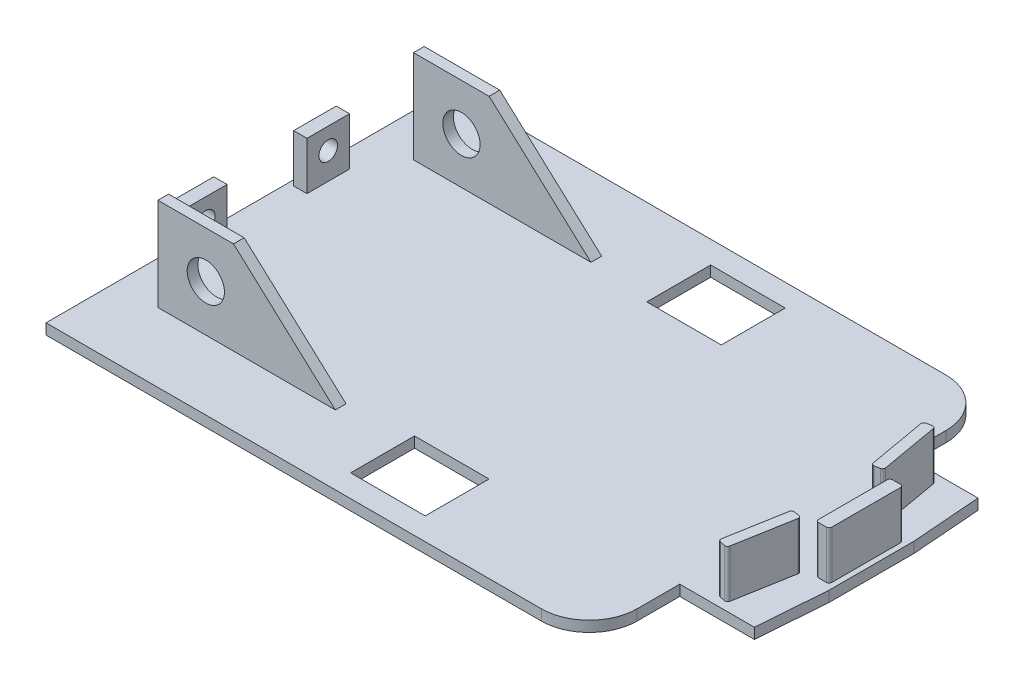
from build123d import *

# Parameters (mm, degrees)
ESBO_O1_W                = 14
ESBO_O1_H                = 12
RESSALTO_EXTRUS_O1_DEPTH = 2
ESBO_O2_W                = 2.5
ESBO_O2_H                = 13.9
RESSALTO_EXTRUS_O2_DEPTH = 9
ESBO_O3_W                = 2.5
ESBO_O3_H                = 8
RESSALTO_EXTRUS_O3_DEPTH = 9
RESSALTO_EXTRUS_O4_START = -15
ESBO_O4_R                = 3.5
RESSALTO_EXTRUS_O4_DEPTH = 2
ESBO_O6_R                = 1.75
CORTE_EXTRUS_O1_DEPTH    = 2.5
FILETE1_R                = 0.5


with BuildPart() as part:
    # Esboço1 → Ressalto-extrusão1 (new body)
    with BuildSketch(Plane(origin=(0, 0, 0), x_dir=(1, 0, 0), z_dir=(0, 1, 0))):
        with BuildLine():
            Line((116, -21), (117, -8))
            Line((117, -8), (117, 8))
            Line((117, 8), (116, 21))
            Line((116, 21), (102, 21))
            Line((102, 21), (102, 29))
            ThreePointArc((102, 29), (99.363961031, 35.363961031), (93, 38))
            Line((93, 38), (0, 38))
            Line((0, 38), (0, -38))
            Line((0, -38), (93, -38))
            ThreePointArc((93, -38), (99.363961031, -35.363961031), (102, -29))
            Line((102, -29), (102, -21))
            Line((102, -21), (116, -21))
        make_face()
        with Locations((60, -27.8)):
            Rectangle(ESBO_O1_W, ESBO_O1_H, mode=Mode.SUBTRACT)
        with Locations((60, 27.8)):
            Rectangle(ESBO_O1_W, ESBO_O1_H, mode=Mode.SUBTRACT)
    extrude(amount=RESSALTO_EXTRUS_O1_DEPTH)

    # Esboço2 → Ressalto-extrusão2 (add)
    with BuildSketch(Plane(origin=(0, 2, 0), x_dir=(1, 0, 0), z_dir=(0, 1, 0))):
        Polygon((111.5, 7.747296355), (109.530384494, 7.4), (107.446606362, 19.217693036), (109.416221868, 19.564989391), align=None)
        with Locations((114.75, 0)):
            Rectangle(ESBO_O2_W, ESBO_O2_H)
        Polygon((107.446606362, -19.217693036), (109.530384494, -7.4), (111.5, -7.747296355), (109.416221868, -19.564989391), align=None)
    extrude(amount=RESSALTO_EXTRUS_O2_DEPTH)

    # Esboço3 → Ressalto-extrusão3 (add)
    with BuildSketch(Plane(origin=(0, 2, 0), x_dir=(1, 0, 0), z_dir=(0, 1, 0))):
        with Locations((2.25, -11.5)):
            Rectangle(ESBO_O3_W, ESBO_O3_H)
        with Locations((2.25, 11.5)):
            Rectangle(ESBO_O3_W, ESBO_O3_H)
    extrude(amount=RESSALTO_EXTRUS_O3_DEPTH)

    # Esboço4 → Ressalto-extrusão4 (add)
    with BuildSketch(Plane.XY.offset(38).offset(RESSALTO_EXTRUS_O4_START)):
        Polygon((8.00982099, 2), (8.00982099, 19.434528411), (22.205610886, 19.434528411), (41.330494496, 2), align=None)
        with Locations((17.00982099, 10.717264205)):
            Circle(ESBO_O4_R, mode=Mode.SUBTRACT)
    ressalto_extrus_o4 = extrude(amount=RESSALTO_EXTRUS_O4_DEPTH)

    # Espelhar1: Ressalto-extrusão4 across plane
    add(ressalto_extrus_o4.mirror(Plane.XY))

    # Esboço6 → Corte-extrusão1 (cut)
    with BuildSketch(Plane.ZY.offset(-1)):
        with Locations((11.5, 7)):
            Circle(ESBO_O6_R)
    corte_extrus_o1 = extrude(amount=-CORTE_EXTRUS_O1_DEPTH, mode=Mode.SUBTRACT)

    # Espelhar2: Corte-extrusão1 across plane
    add(corte_extrus_o1.mirror(Plane.XY), mode=Mode.SUBTRACT)

    # Filete1
    filete1_edges = [part.edges().sort_by_distance(p)[0] for p in [
        (116, 6.5, 6.95),
        (116, 6.5, -6.95),
        (113.5, 6.5, -6.95),
        (113.5, 6.5, 6.95),
        (111.5, 6.5, -7.747296355),
        (109.416221868, 6.5, -19.564989391),
        (107.446606362, 6.5, -19.217693036),
        (109.530384494, 6.5, -7.4),
        (107.446606362, 6.5, 19.217693036),
        (109.416221868, 6.5, 19.564989391),
        (111.5, 6.5, 7.747296355),
        (109.530384494, 6.5, 7.4),
    ]]
    fillet(filete1_edges, radius=FILETE1_R)


solid = part.part
